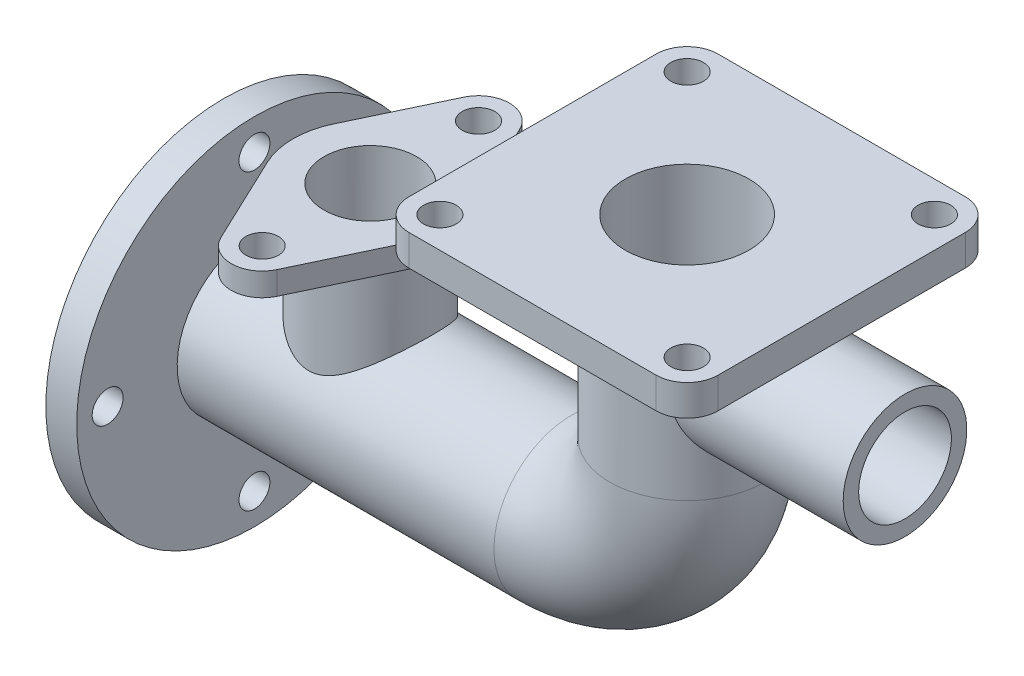
from build123d import *

# Parameters (mm, degrees)
SKETCH1_R           = 12.5
SKETCH1_R_2         = 10
BOSS_EXTRUDE1_START = -5
SKETCH3_R           = 2.64
SKETCH3_R_2         = 12.5
BOSS_EXTRUDE1_DEPTH = 5
SKETCH4_W           = 35.25
SKETCH4_H           = 2.5
SKETCH5_W           = 35.25
SKETCH5_H           = 7.5
SKETCH7_W           = 2.5
SKETCH7_H           = 28.75
SKETCH8_W           = 7.5
SKETCH8_H           = 28.75
SKETCH9_R           = 2.64
SKETCH9_R_2         = 10
BOSS_EXTRUDE2_DEPTH = 3.75
SKETCH10_R          = 28.75
SKETCH10_R_2        = 2.5
SKETCH10_R_3        = 12.5
BOSS_EXTRUDE3_DEPTH = 5
SKETCH11_R          = 10


with BuildPart() as part:
    # Sweep1: sweep along a path in Sketch2
    with BuildLine(Plane.XY) as sweep1_path:
        Line((0, 0), (0, -31.25))
        ThreePointArc((0, -31.25), (-5.491747853, -44.508252147), (-18.75, -50))
        Line((-18.75, -50), (-75, -50))
    # Sketch1 → Sweep1 (sweep)
    with BuildSketch(Plane(origin=(0, 0, 0), x_dir=(1, 0, 0), z_dir=(0, 1, 0))):
        Circle(SKETCH1_R)
        Circle(SKETCH1_R_2, mode=Mode.SUBTRACT)
    sweep(path=sweep1_path.line)

    # Sketch3 → Boss-Extrude1 (add)
    with BuildSketch(Plane(origin=(0, 0, 0), x_dir=(1, 0, 0), z_dir=(0, 1, 0)).offset(BOSS_EXTRUDE1_START)):
        with BuildLine():
            Line((-20, 25), (20, 25))
            ThreePointArc((20, 25), (23.535533906, 23.535533906), (25, 20))
            Line((25, 20), (25, -20))
            ThreePointArc((25, -20), (23.535533906, -23.535533906), (20, -25))
            Line((20, -25), (-20, -25))
            ThreePointArc((-20, -25), (-23.535533906, -23.535533906), (-25, -20))
            Line((-25, -20), (-25, 20))
            ThreePointArc((-25, 20), (-23.535533906, 23.535533906), (-20, 25))
        make_face()
        with Locations((-20, 20)):
            Circle(SKETCH3_R, mode=Mode.SUBTRACT)
        with Locations((20, 20)):
            Circle(SKETCH3_R, mode=Mode.SUBTRACT)
        with Locations((-20, -20)):
            Circle(SKETCH3_R, mode=Mode.SUBTRACT)
        with Locations((20, -20)):
            Circle(SKETCH3_R, mode=Mode.SUBTRACT)
        Circle(SKETCH3_R_2, mode=Mode.SUBTRACT)
    extrude(amount=BOSS_EXTRUDE1_DEPTH)

    # Sketch4 → Revolve1 (revolve)
    with BuildSketch(Plane.XY):
        with Locations((17.625, -8.75)):
            Rectangle(SKETCH4_W, SKETCH4_H)
    revolve(axis=Axis((0, -17.5, 0), (1, 0, 0)))

    # Sketch5 → Cut-Revolve1 (revolve, cut)
    with BuildSketch(Plane.XY):
        with Locations((17.625, -13.75)):
            Rectangle(SKETCH5_W, SKETCH5_H)
    revolve(axis=Axis((0, -17.5, 0), (1, 0, 0)), mode=Mode.SUBTRACT)

    # Sketch7 → Revolve2 (revolve)
    with BuildSketch(Plane.XY):
        with Locations((-60, -35.625)):
            Rectangle(SKETCH7_W, SKETCH7_H)
    revolve(axis=Axis((-51.25, -50, 0), (0, 1, 0)))

    # Sketch8 → Cut-Revolve2 (revolve, cut)
    with BuildSketch(Plane.XY):
        with Locations((-55, -35.625)):
            Rectangle(SKETCH8_W, SKETCH8_H)
    revolve(axis=Axis((-51.25, -21.25, 0), (0, -1, 0)), mode=Mode.SUBTRACT)

    # Sketch9 → Boss-Extrude2 (add)
    with BuildSketch(Plane(origin=(0, -21.25, 0), x_dir=(1, 0, 0), z_dir=(0, 1, 0))):
        with BuildLine():
            Line((-55.767539515, 19.642857143), (-62.543848786, 5.357142857))
            ThreePointArc((-62.543848786, 5.357142857), (-63.75, 0), (-62.543848786, -5.357142857))
            Line((-62.543848786, -5.357142857), (-55.767539515, -19.642857143))
            ThreePointArc((-55.767539515, -19.642857143), (-51.25, -22.5), (-46.732460485, -19.642857143))
            Line((-46.732460485, -19.642857143), (-39.956151214, -5.357142857))
            ThreePointArc((-39.956151214, -5.357142857), (-38.75, 0), (-39.956151214, 5.357142857))
            Line((-39.956151214, 5.357142857), (-46.732460485, 19.642857143))
            ThreePointArc((-46.732460485, 19.642857143), (-51.25, 22.5), (-55.767539515, 19.642857143))
        make_face()
        with Locations((-51.25, 17.5)):
            Circle(SKETCH9_R, mode=Mode.SUBTRACT)
        with Locations((-51.25, -17.5)):
            Circle(SKETCH9_R, mode=Mode.SUBTRACT)
        with Locations((-51.25, 0)):
            Circle(SKETCH9_R_2, mode=Mode.SUBTRACT)
    extrude(amount=-BOSS_EXTRUDE2_DEPTH)

    # Sketch10 → Boss-Extrude3 (add)
    with BuildSketch(Plane.ZY.offset(75)):
        with Locations((0, -50)):
            Circle(SKETCH10_R)
        with Locations((0, -26.25)):
            Circle(SKETCH10_R_2, mode=Mode.SUBTRACT)
        with Locations((23.75, -50)):
            Circle(SKETCH10_R_2, mode=Mode.SUBTRACT)
        with Locations((0, -73.75)):
            Circle(SKETCH10_R_2, mode=Mode.SUBTRACT)
        with Locations((-23.75, -50)):
            Circle(SKETCH10_R_2, mode=Mode.SUBTRACT)
        with Locations((0, -50)):
            Circle(SKETCH10_R_3, mode=Mode.SUBTRACT)
    extrude(amount=-BOSS_EXTRUDE3_DEPTH)

    # Cut-Sweep1: sweep along a path in Sketch2_2
    with BuildLine(Plane.XY) as cut_sweep1_path:
        Line((0, 0), (0, -31.25))
        ThreePointArc((0, -31.25), (-5.491747853, -44.508252147), (-18.75, -50))
        Line((-18.75, -50), (-75, -50))
    # Sketch11 → Cut-Sweep1 (sweep, cut)
    with BuildSketch(Plane(origin=(0, 0, 0), x_dir=(1, 0, 0), z_dir=(0, 1, 0))):
        Circle(SKETCH11_R)
    sweep(path=cut_sweep1_path.line, mode=Mode.SUBTRACT)


solid = part.part
